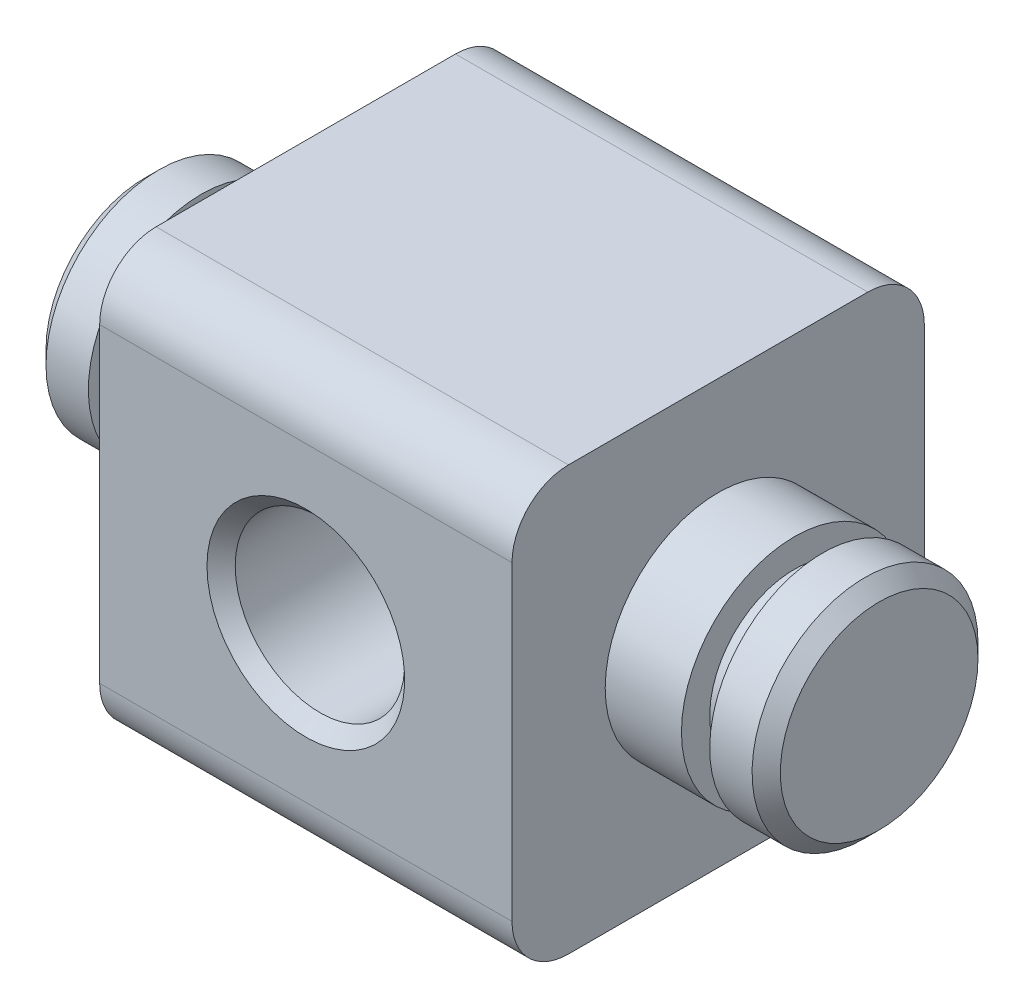
from build123d import *

# Parameters (mm, degrees)
SKETCH1_W                = 14.6
SKETCH1_H                = 14.6
BOSS_EXTRUDE1_DEPTH      = 15
SKETCH2_R                = 3
CUT_EXTRUDE1_DEPTH       = 14.6
CHAMFER1_SIZE            = 0.5
SKETCH3_R                = 4
BOSS_EXTRUDE2_DEPTH      = 5.7
SKETCH4_W                = 1
SKETCH4_H                = 1.778268535
CHAMFER2_SIZE            = 0.5
CHAMFER2_OF_MIRROR1_SIZE = 0.5
FILLET1_R                = 2


with BuildPart() as part:
    # Sketch1 → Boss-Extrude1 (new body)
    with BuildSketch(Plane(origin=(0, 0, 0), x_dir=(1, 0, 0), z_dir=(0, 1, 0))):
        Rectangle(SKETCH1_W, SKETCH1_H)
    extrude(amount=BOSS_EXTRUDE1_DEPTH)

    # Sketch2 → Cut-Extrude1 (cut)
    with BuildSketch(Plane(origin=(0, 7.7, -7.3), x_dir=(1, 0, 0), z_dir=(0, 0, 1))):
        with Locations((0, -0.2)):
            Circle(SKETCH2_R)
    extrude(amount=CUT_EXTRUDE1_DEPTH, mode=Mode.SUBTRACT)

    # Chamfer1
    chamfer1_edges = [part.edges().sort_by_distance(p)[0] for p in [
        (-3, 7.5, -7.3),
        (-3, 7.5, 7.3),
    ]]
    chamfer(chamfer1_edges, length=CHAMFER1_SIZE)

    # Sketch3 → Boss-Extrude2 (add)
    with BuildSketch(Plane.ZY.offset(7.3)):
        with Locations((0, 7.5)):
            Circle(SKETCH3_R)
    boss_extrude2 = extrude(amount=BOSS_EXTRUDE2_DEPTH)

    # Sketch4 → Cut-Revolve1 (revolve, cut)
    with BuildSketch(Plane.XY):
        with Locations((-10.5, 11.389134268)):
            Rectangle(SKETCH4_W, SKETCH4_H)
    cut_revolve1 = revolve(axis=Axis((-13, 7.5, 0), (1, 0, 0)), mode=Mode.SUBTRACT)

    # Chamfer2
    chamfer2_edges = [part.edges().sort_by_distance(p)[0] for p in [
        (-13, 7.5, -4),
    ]]
    chamfer(chamfer2_edges, length=CHAMFER2_SIZE)

    # Mirror1: Boss-Extrude2, Cut-Revolve1 across plane
    add(boss_extrude2.mirror(Plane(origin=(0, 0, 0), x_dir=(0, 0, 1), z_dir=(1, 0, 0))))
    add(cut_revolve1.mirror(Plane(origin=(0, 0, 0), x_dir=(0, 0, 1), z_dir=(1, 0, 0))), mode=Mode.SUBTRACT)

    # Chamfer2 of Mirror1
    chamfer2_of_mirror1_edges = [part.edges().sort_by_distance(p)[0] for p in [
        (13, 7.5, -4),
    ]]
    chamfer(chamfer2_of_mirror1_edges, length=CHAMFER2_OF_MIRROR1_SIZE)

    # Fillet1
    fillet1_edges = [part.edges().sort_by_distance(p)[0] for p in [
        (0, 15, -7.3),
        (0, 0, -7.3),
        (0, 0, 7.3),
        (0, 15, 7.3),
    ]]
    fillet(fillet1_edges, radius=FILLET1_R)


solid = part.part
